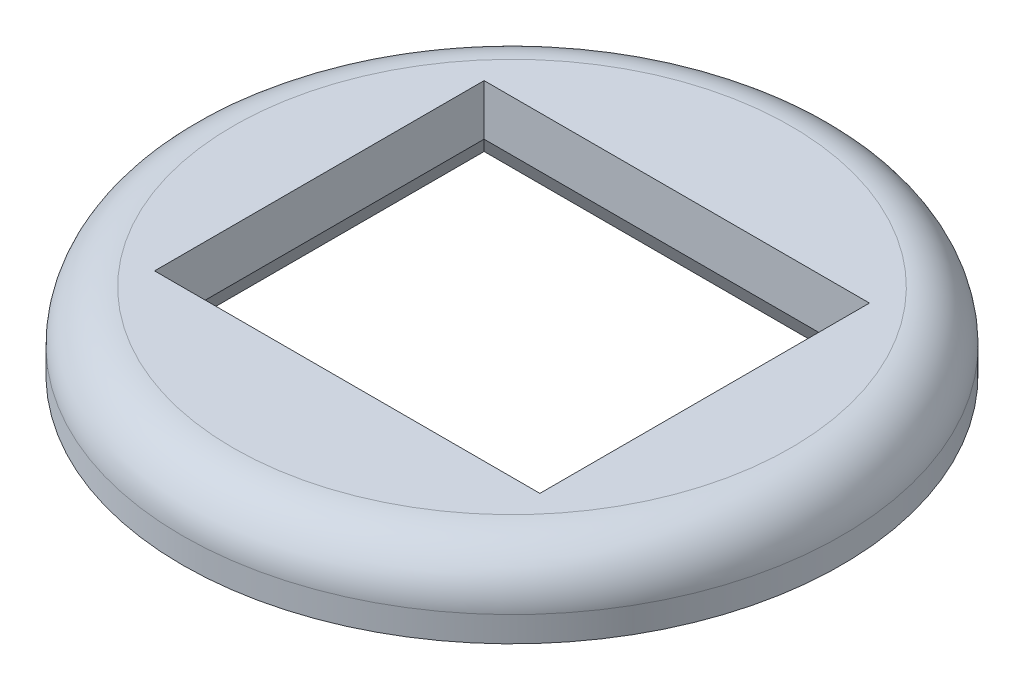
from build123d import *

# Parameters (mm, degrees)
SKETCH1_R             = 13
SKETCH1_W             = 15.2
SKETCH1_H             = 13
BOSS_EXTRUDE1_DEPTH   = 3
FILLET1_R             = 2
CHAMFER1_SIZE         = 1
CHAMFER1_SIZE2        = 0.577350269
CHAMFER1_PART_2_SIZE  = 1
CHAMFER1_PART_2_SIZE2 = 0.577350269
CHAMFER1_PART_3_SIZE  = 1
CHAMFER1_PART_3_SIZE2 = 0.577350269
CHAMFER1_PART_4_SIZE  = 1
CHAMFER1_PART_4_SIZE2 = 0.577350269


with BuildPart() as part:
    # Sketch1 → Boss-Extrude1 (new body)
    with BuildSketch(Plane(origin=(0, 0, 0), x_dir=(1, 0, 0), z_dir=(0, 1, 0))):
        Circle(SKETCH1_R)
        Rectangle(SKETCH1_W, SKETCH1_H, mode=Mode.SUBTRACT)
    extrude(amount=BOSS_EXTRUDE1_DEPTH)

    # Fillet1
    fillet1_edges = [part.edges().sort_by_distance(p)[0] for p in [
        (-13, 3, 0),
    ]]
    fillet(fillet1_edges, radius=FILLET1_R)

    # Chamfer1
    chamfer1_edges = [part.edges().sort_by_distance(p)[0] for p in [
        (-7.6, 0, 0),
    ]]
    chamfer1_side = [part.faces().sort_by_distance(p)[0] for p in [
        (-7.6, 1.5, 0),
    ]]
    chamfer(chamfer1_edges, length=CHAMFER1_SIZE, length2=CHAMFER1_SIZE2, reference=chamfer1_side[0])

    # Chamfer1 part 2
    chamfer1_part_2_edges = [part.edges().sort_by_distance(p)[0] for p in [
        (0, 0, 6.5),
    ]]
    chamfer1_part_2_side = [part.faces().sort_by_distance(p)[0] for p in [
        (0, 1.5, 6.5),
    ]]
    chamfer(chamfer1_part_2_edges, length=CHAMFER1_PART_2_SIZE, length2=CHAMFER1_PART_2_SIZE2, reference=chamfer1_part_2_side[0])

    # Chamfer1 part 3
    chamfer1_part_3_edges = [part.edges().sort_by_distance(p)[0] for p in [
        (7.6, 0, 0),
    ]]
    chamfer1_part_3_side = [part.faces().sort_by_distance(p)[0] for p in [
        (7.6, 1.5, 0),
    ]]
    chamfer(chamfer1_part_3_edges, length=CHAMFER1_PART_3_SIZE, length2=CHAMFER1_PART_3_SIZE2, reference=chamfer1_part_3_side[0])

    # Chamfer1 part 4
    chamfer1_part_4_edges = [part.edges().sort_by_distance(p)[0] for p in [
        (0, 0, -6.5),
    ]]
    chamfer1_part_4_side = [part.faces().sort_by_distance(p)[0] for p in [
        (0, 1.5, -6.5),
    ]]
    chamfer(chamfer1_part_4_edges, length=CHAMFER1_PART_4_SIZE, length2=CHAMFER1_PART_4_SIZE2, reference=chamfer1_part_4_side[0])


solid = part.part
